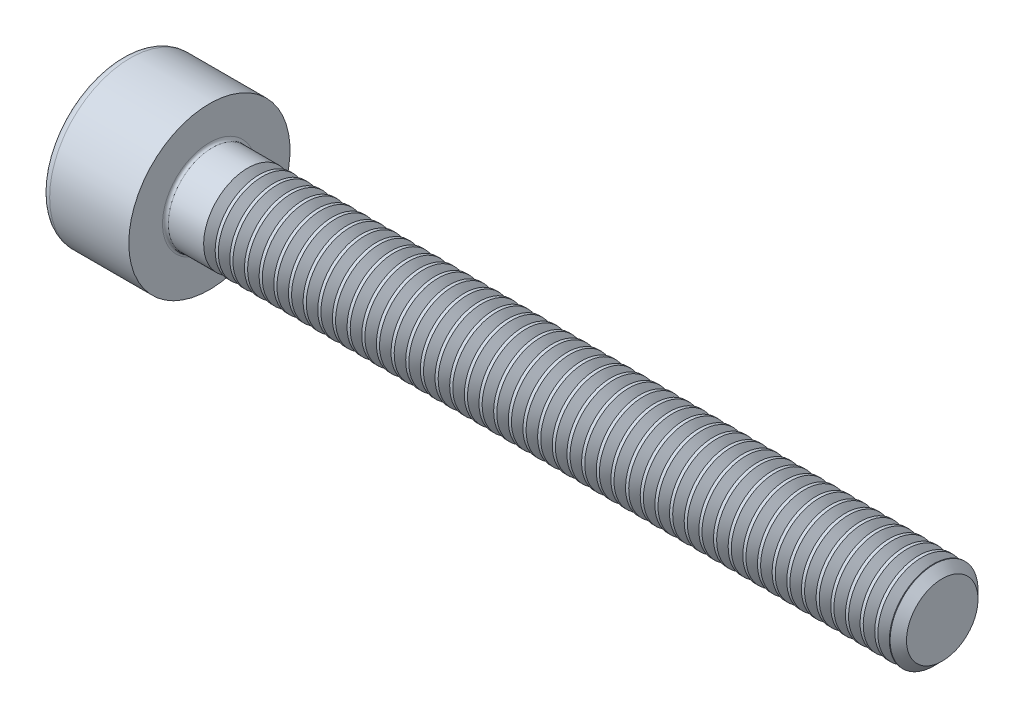
from build123d import *

# Parameters (mm, degrees)
FILLET1_R       = 0.1
FILLET2_R       = 0.3
HEX_2_DEPTH     = 1.3
THDSCHPAT_COUNT = 47
THDSCHPAT_PITCH = 0.5


with BuildPart() as part:
    # BodySke → Base-Revolve (revolve)
    with BuildSketch(Plane.XY, mode=Mode.PRIVATE) as base_revolve_sk:
        Polygon((0, 0), (0, 2.75), (3, 2.75), (3, 1.5), (27.7195, 1.5), (28, 1.2195), (28, 0), align=None)
    revolve(base_revolve_sk.sketch.rotate(Axis((-31.75, 0, 0), (1, 0, 0)), 90), axis=Axis((-31.75, 0, 0), (1, 0, 0)))  # turned: the seam where the file's is

    # Fillet1
    fillet1_edges = [part.edges().sort_by_distance(p)[0] for p in [
        (3, 0, -1.5),
    ]]
    fillet(fillet1_edges, radius=FILLET1_R)

    # Fillet2
    fillet2_edges = [part.edges().sort_by_distance(p)[0] for p in [
        (0, 0, -2.75),
    ]]
    fillet(fillet2_edges, radius=FILLET2_R)

    # Sketch2 → Hex-PreBroach (revolve, cut)
    with BuildSketch(Plane.XY, mode=Mode.PRIVATE) as hex_prebroach_sk:
        Polygon((0, 1.26), (1.3, 1.26), (2.027461339, 0), (0, 0), align=None)
    revolve(hex_prebroach_sk.sketch.rotate(Axis((0, 0, 0), (1, 0, 0)), 90), axis=Axis((0, 0, 0), (1, 0, 0)), mode=Mode.SUBTRACT)  # turned: the seam where the file's is

    # Sketch3 → Hex 2 (cut)
    with BuildSketch(Plane(origin=(0, 0, 0), x_dir=(0, 0.5, 0.866025404), z_dir=(-1, 0, 0))):
        Polygon((0.727461339, 1.26), (-0.727461339, 1.26), (-1.454922678, 0), (-0.727461339, -1.26), (0.727461339, -1.26), (1.454922678, 0), align=None)
    extrude(amount=-HEX_2_DEPTH, mode=Mode.SUBTRACT)

    # ThdSchSke → ThreadSchematic (revolve, cut)
    with BuildSketch(Plane.XY, mode=Mode.PRIVATE) as threadschematic_sk:
        Polygon((4.5, -1.2195), (4.303591786, -1.5), (4.303591786, -1.875), (4.696408214, -1.875), (4.696408214, -1.5), align=None)
    threadschematic = revolve(threadschematic_sk.sketch.rotate(Axis((-3.175, 0, 0), (1, 0, 0)), 270), axis=Axis((-3.175, 0, 0), (1, 0, 0)), mode=Mode.SUBTRACT)  # turned: the seam where the file's is

    # ThdSchPat: ThreadSchematic ×47
    with Locations(*[(i * THDSCHPAT_PITCH, 0, 0) for i in range(1, THDSCHPAT_COUNT)]):
        add(threadschematic, mode=Mode.SUBTRACT)


solid = part.part
